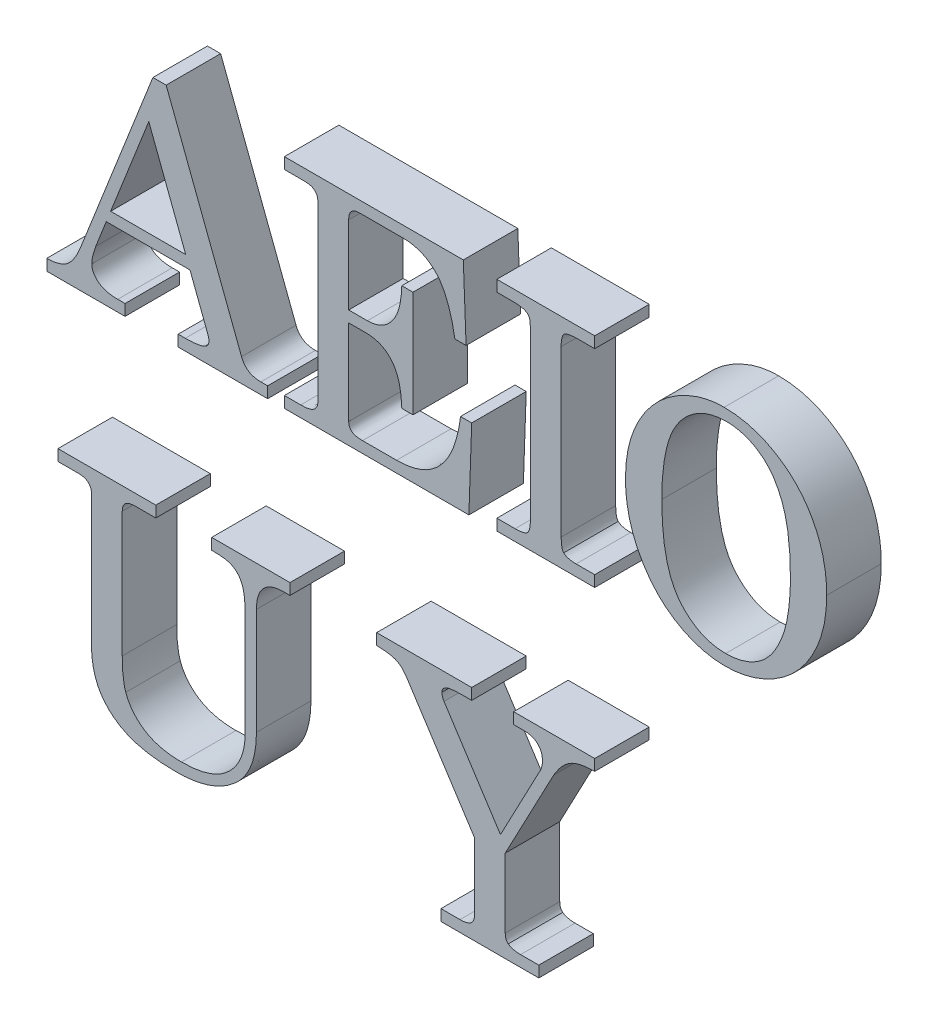
from build123d import *

# Parameters (mm, degrees)
BOSS_EXTRU_1_DEPTH   = 10
BOSS_EXTRU_1_2_DEPTH = 10
BOSS_EXTRU_1_3_DEPTH = 10
BOSS_EXTRU_1_4_DEPTH = 10
BOSS_EXTRU_1_5_DEPTH = 10
BOSS_EXTRU_1_6_DEPTH = 10


with BuildPart() as part:
    # Esquisse1 → Boss.-Extru.1 (new body)
    with BuildSketch(Plane.XY):
        with BuildLine():
            Line((18.958333333, 40.512820513), (21.386217949, 40.512820513))
            Line((21.386217949, 40.512820513), (35.216346154, 4.294871795))
            add(Edge.make_bspline(
                [(35.216346154, 4.294871795), (35.293715697, 4.115735313), (35.44230231, 3.771707393), (35.750096979, 3.310828226), (36.106440865, 2.913571643), (36.534302745, 2.602066852), (37.004103329, 2.341378765), (37.543609805, 2.185182043), (38.130146652, 2.062135417), (38.543575461, 2.05498884), (38.758012821, 2.051282051)],
                knots=[0, 0, 0, 0, 0.000584277, 0.001122092, 0.00165517, 0.002176004, 0.002702965, 0.003257936, 0.003853531, 0.004495358, 0.004495358, 0.004495358, 0.004495358], degree=3))
            Line((38.758012821, 2.051282051), (40, 2.051282051))
            Line((40, 2.051282051), (40, 0))
            Line((40, 0), (23.58974359, 0))
            Line((23.58974359, 0), (23.58974359, 2.051282051))
            Line((23.58974359, 2.051282051), (24.895833333, 2.051282051))
            add(Edge.make_bspline(
                [(24.895833333, 2.051282051), (25.291606746, 2.055123883), (26.023328427, 2.062226816), (27.024118043, 2.168609824), (27.851103363, 2.313529654), (28.311555136, 2.508773405), (28.517628205, 2.596153846)],
                knots=[0, 0, 0, 0, 0.00118633, 0.002193335, 0.003019938, 0.003689572, 0.003689572, 0.003689572, 0.003689572], degree=3))
            add(Edge.make_bspline(
                [(28.517628205, 2.596153846), (28.62577153, 2.663019754), (28.835796861, 2.792880145), (29.078001573, 3.070648089), (29.209963564, 3.411055425), (29.22894197, 3.650097789), (29.238782051, 3.774038462)],
                knots=[0, 0, 0, 0, 0.000380081, 0.000738157, 0.00108336, 0.001455072, 0.001455072, 0.001455072, 0.001455072], degree=3))
            add(Edge.make_bspline(
                [(29.238782051, 3.774038462), (29.230043341, 3.935743885), (29.211768342, 4.273913504), (29.097887182, 4.593071739), (29.038461538, 4.759615385)],
                knots=[0, 0, 0, 0, 0.000483167, 0.001010433, 0.001010433, 0.001010433, 0.001010433], degree=3))
            Line((29.038461538, 4.759615385), (25.761217949, 13.333333333))
            Line((25.761217949, 13.333333333), (10.400641026, 13.333333333))
            Line((10.400641026, 13.333333333), (8.461538462, 8.413461538))
            add(Edge.make_bspline(
                [(8.461538462, 8.413461538), (8.353429909, 8.104853668), (8.151031127, 7.527083869), (7.925051261, 6.697839454), (7.776589784, 5.969414445), (7.751757893, 5.513363495), (7.740384615, 5.304487179)],
                knots=[0, 0, 0, 0, 0.000980613, 0.001835886, 0.002577667, 0.003204513, 0.003204513, 0.003204513, 0.003204513], degree=3))
            add(Edge.make_bspline(
                [(7.740384615, 5.304487179), (7.756259332, 5.086133156), (7.787523509, 4.656099706), (8.027136272, 4.036769056), (8.425811573, 3.48094597), (8.958560052, 2.968733828), (9.648902819, 2.551144519), (10.483918637, 2.261888131), (11.449946708, 2.072995513), (12.141079245, 2.058812203), (12.508012821, 2.051282051)],
                knots=[0, 0, 0, 0, 0.000653966, 0.001287942, 0.001961448, 0.002692549, 0.003490981, 0.0043604, 0.005331572, 0.006430761, 0.006430761, 0.006430761, 0.006430761], degree=3))
            Line((12.508012821, 2.051282051), (13.846153846, 2.051282051))
            Line((13.846153846, 2.051282051), (13.846153846, 0))
            Line((13.846153846, 0), (-0.512820513, 0))
            Line((-0.512820513, 0), (-0.512820513, 2.051282051))
            add(Edge.make_bspline(
                [(-0.512820513, 2.051282051), (-0.140620362, 2.062217567), (0.569217706, 2.083073134), (1.574710131, 2.276651261), (2.461978241, 2.592649194), (3.245588282, 3.060757534), (3.946666124, 3.72030566), (4.573405617, 4.604912331), (5.199502453, 5.696468471), (5.544058395, 6.525673859), (5.729166667, 6.971153846)],
                knots=[0, 0, 0, 0, 0.001115625, 0.002127654, 0.003058004, 0.003927866, 0.004846375, 0.005923317, 0.007168634, 0.008614365, 0.008614365, 0.008614365, 0.008614365], degree=3))
            Line((5.729166667, 6.971153846), (18.958333333, 40.512820513))
        make_face()
        Polygon((18.205128205, 33.125), (11.209935897, 15.384615385), (24.975961538, 15.384615385), align=None, mode=Mode.SUBTRACT)
    extrude(amount=BOSS_EXTRU_1_DEPTH)


with BuildPart() as body_2:
    # Esquisse1 → Boss.-Extru.1 2 (new body)
    with BuildSketch(Plane.XY):
        with BuildLine():
            Line((43.076923077, 40), (75.897435897, 40))
            Line((75.897435897, 40), (76.41025641, 26.666666667))
            Line((76.41025641, 26.666666667), (74.358974359, 26.666666667))
            add(Edge.make_bspline(
                [(74.358974359, 26.666666667), (74.268447848, 27.17266094), (74.093700135, 28.149406206), (73.750130155, 29.542283249), (73.391403829, 30.822918054), (72.968339364, 31.977636571), (72.529218095, 33.026560758), (72.02879529, 33.947740228), (71.504405545, 34.761705441), (70.918646454, 35.449732265), (70.292576846, 36.038991711), (69.638062987, 36.55746773), (68.928523503, 36.986290996), (68.17670044, 37.339245577), (67.377303381, 37.609365805), (66.539409712, 37.815459432), (65.65190403, 37.924080679), (65.04566666, 37.940380572), (64.735576923, 37.948717949)],
                knots=[0, 0, 0, 0, 0.001541651, 0.002975923, 0.004302209, 0.005528982, 0.006663185, 0.007710047, 0.008670115, 0.009562709, 0.010412899, 0.011246386, 0.012062672, 0.012894309, 0.013733056, 0.014590129, 0.015478649, 0.016408999, 0.016408999, 0.016408999, 0.016408999], degree=3))
            Line((64.735576923, 37.948717949), (56.810897436, 37.948717949))
            add(Edge.make_bspline(
                [(56.810897436, 37.948717949), (56.660945513, 37.942918979), (56.376251641, 37.931909244), (55.974395738, 37.840490617), (55.638214311, 37.662842227), (55.348566079, 37.439451283), (55.125100155, 37.137960678), (54.975317557, 36.76890772), (54.888876531, 36.334070668), (54.877744089, 36.023396958), (54.871794872, 35.857371795)],
                knots=[0, 0, 0, 0, 0.000449861, 0.000854092, 0.001223204, 0.001582353, 0.00194293, 0.00233433, 0.00276806, 0.003265888, 0.003265888, 0.003265888, 0.003265888], degree=3))
            Line((54.871794872, 35.857371795), (54.871794872, 21.538461538))
            Line((54.871794872, 21.538461538), (58.301282051, 21.538461538))
            add(Edge.make_bspline(
                [(58.301282051, 21.538461538), (58.526123644, 21.543428941), (58.965024753, 21.553125539), (59.606571218, 21.664212867), (60.216917845, 21.830459608), (60.796247765, 22.062410822), (61.34168821, 22.364856802), (61.853802951, 22.732130031), (62.331095081, 23.174096627), (62.779466781, 23.67460386), (63.183799825, 24.253492608), (63.542737563, 24.899742944), (63.846932384, 25.620862988), (64.101581224, 26.409413548), (64.311756443, 27.268582132), (64.45564057, 28.202127659), (64.574935724, 29.20400333), (64.601614265, 29.898130675), (64.615384615, 30.256410256)],
                knots=[0, 0, 0, 0, 0.00067384, 0.001315366, 0.00194716, 0.002569123, 0.003182404, 0.003813945, 0.00445482, 0.00513023, 0.005826055, 0.006568528, 0.007343952, 0.008170012, 0.009052332, 0.009994205, 0.01100207, 0.012077252, 0.012077252, 0.012077252, 0.012077252], degree=3))
            Line((64.615384615, 30.256410256), (66.666666667, 30.256410256))
            Line((66.666666667, 30.256410256), (66.666666667, 10.769230769))
            Line((66.666666667, 10.769230769), (64.615384615, 10.769230769))
            add(Edge.make_bspline(
                [(64.615384615, 10.769230769), (64.601473179, 11.146158308), (64.574677301, 11.872187152), (64.45880437, 12.917794892), (64.303015509, 13.879294898), (64.09434979, 14.757694864), (63.842193631, 15.556793618), (63.528068756, 16.272557884), (63.170608616, 16.909970247), (62.757064654, 17.464198381), (62.292598974, 17.934558035), (61.806720998, 18.362940279), (61.261710517, 18.700431766), (60.691137736, 19.000448919), (60.069485632, 19.20816999), (59.416756688, 19.372753531), (58.723494881, 19.469658774), (58.248159053, 19.481246879), (58.004807692, 19.487179487)],
                knots=[0, 0, 0, 0, 0.001131199, 0.002178889, 0.003153691, 0.004051591, 0.004885271, 0.005663877, 0.006392383, 0.007073472, 0.007730817, 0.008373093, 0.009011006, 0.009648869, 0.010302688, 0.010971218, 0.011666997, 0.012396868, 0.012396868, 0.012396868, 0.012396868], degree=3))
            Line((58.004807692, 19.487179487), (54.871794872, 19.487179487))
            Line((54.871794872, 19.487179487), (54.871794872, 3.814102564))
            add(Edge.make_bspline(
                [(54.871794872, 3.814102564), (54.880235575, 3.679986785), (54.896383076, 3.423416368), (54.998873707, 3.057423088), (55.191260036, 2.746773791), (55.453121853, 2.477156401), (55.818586023, 2.287598488), (56.264142245, 2.142374842), (56.808804406, 2.071312617), (57.20073488, 2.058294576), (57.411858974, 2.051282051)],
                knots=[0, 0, 0, 0, 0.000402639, 0.00077027, 0.001126187, 0.001488806, 0.001883391, 0.002347098, 0.002889903, 0.003523727, 0.003523727, 0.003523727, 0.003523727], degree=3))
            Line((57.411858974, 2.051282051), (63.653846154, 2.051282051))
            add(Edge.make_bspline(
                [(63.653846154, 2.051282051), (64.068374023, 2.059207302), (64.876358178, 2.07465494), (66.050830084, 2.232498161), (67.160559857, 2.478109644), (68.20213682, 2.831568957), (69.181112804, 3.279197307), (70.083218731, 3.839604986), (70.924213634, 4.491945659), (71.694212491, 5.248698373), (72.396521673, 6.10659886), (73.027490702, 7.064958056), (73.600016825, 8.119298153), (74.094403765, 9.276699645), (74.515492075, 10.535723831), (74.884801289, 11.888206826), (75.183075623, 13.344172809), (75.316123097, 14.352640095), (75.384615385, 14.871794872)],
                knots=[0, 0, 0, 0, 0.001242917, 0.002422654, 0.003548163, 0.004647877, 0.005716229, 0.006770304, 0.007826569, 0.008903153, 0.010001962, 0.011146477, 0.012340415, 0.013596665, 0.014916837, 0.01632027, 0.017800583, 0.019371178, 0.019371178, 0.019371178, 0.019371178], degree=3))
            Line((75.384615385, 14.871794872), (77.435897436, 14.871794872))
            Line((77.435897436, 14.871794872), (76.923076923, 0))
            Line((76.923076923, 0), (43.076923077, 0))
            Line((43.076923077, 0), (43.076923077, 2.051282051))
            Line((43.076923077, 2.051282051), (46.065705128, 2.051282051))
            add(Edge.make_bspline(
                [(46.065705128, 2.051282051), (46.33582522, 2.055845574), (46.835737316, 2.0642913), (47.521600535, 2.162877559), (48.079932032, 2.33421237), (48.517422879, 2.579131147), (48.846005558, 2.897018939), (49.073681868, 3.281751247), (49.202991927, 3.731341508), (49.221204608, 4.048292637), (49.230769231, 4.21474359)],
                knots=[0, 0, 0, 0, 0.000809929, 0.001498939, 0.002071617, 0.002552653, 0.002988966, 0.003427334, 0.00387862, 0.004377736, 0.004377736, 0.004377736, 0.004377736], degree=3))
            Line((49.230769231, 4.21474359), (49.230769231, 35.865384615))
            add(Edge.make_bspline(
                [(49.230769231, 35.865384615), (49.223263492, 36.031571844), (49.209142958, 36.344219575), (49.099387208, 36.785400697), (48.894902682, 37.153213148), (48.611471993, 37.454003933), (48.244718809, 37.682749473), (47.791156294, 37.840540525), (47.252669034, 37.932997837), (46.864709821, 37.943264851), (46.658653846, 37.948717949)],
                knots=[0, 0, 0, 0, 0.000498408, 0.000937654, 0.001350139, 0.001746915, 0.002164813, 0.002633751, 0.003179153, 0.003796972, 0.003796972, 0.003796972, 0.003796972], degree=3))
            Line((46.658653846, 37.948717949), (43.076923077, 37.948717949))
            Line((43.076923077, 37.948717949), (43.076923077, 40))
        make_face()
    extrude(amount=BOSS_EXTRU_1_2_DEPTH)


with BuildPart() as body_3:
    # Esquisse1 → Boss.-Extru.1 3 (new body)
    with BuildSketch(Plane.XY):
        with BuildLine():
            Line((82.051282051, 40), (100, 40))
            Line((100, 40), (100, 37.948717949))
            Line((100, 37.948717949), (96.947115385, 37.948717949))
            add(Edge.make_bspline(
                [(96.947115385, 37.948717949), (96.639733319, 37.943734096), (96.084512475, 37.934731817), (95.339579041, 37.847454955), (94.774433809, 37.693560287), (94.356712631, 37.448620186), (94.108092367, 37.061136317), (93.960450623, 36.561359336), (93.856597721, 35.925600318), (93.849851205, 35.451909208), (93.846153846, 35.192307692)],
                knots=[0, 0, 0, 0, 0.000922032, 0.001665456, 0.002243379, 0.002672346, 0.003081314, 0.003588089, 0.004229615, 0.00500752, 0.00500752, 0.00500752, 0.00500752], degree=3))
            Line((93.846153846, 35.192307692), (93.846153846, 4.943910256))
            add(Edge.make_bspline(
                [(93.846153846, 4.943910256), (93.851171928, 4.670753701), (93.860257165, 4.176203835), (93.947020916, 3.523516419), (94.06456871, 3.012486169), (94.242678841, 2.777049371), (94.318910256, 2.676282051)],
                knots=[0, 0, 0, 0, 0.000817936, 0.001480873, 0.001982811, 0.002358389, 0.002358389, 0.002358389, 0.002358389], degree=3))
            add(Edge.make_bspline(
                [(94.318910256, 2.676282051), (94.440089243, 2.577921871), (94.702100351, 2.365249191), (95.229801907, 2.190801553), (95.864568108, 2.06688902), (96.33186993, 2.056787269), (96.586538462, 2.051282051)],
                knots=[0, 0, 0, 0, 0.000464813, 0.00100501, 0.001641462, 0.002403733, 0.002403733, 0.002403733, 0.002403733], degree=3))
            Line((96.586538462, 2.051282051), (100, 2.051282051))
            Line((100, 2.051282051), (100, 0))
            Line((100, 0), (82.051282051, 0))
            Line((82.051282051, 0), (82.051282051, 2.051282051))
            Line((82.051282051, 2.051282051), (85.400641026, 2.051282051))
            add(Edge.make_bspline(
                [(85.400641026, 2.051282051), (85.668148807, 2.055177851), (86.154935464, 2.062267079), (86.811104782, 2.163573984), (87.31955583, 2.319405366), (87.711442693, 2.566619643), (87.94182072, 2.97305116), (88.103678677, 3.492421091), (88.190630061, 4.169439769), (88.199975307, 4.668649694), (88.205128205, 4.943910256)],
                knots=[0, 0, 0, 0, 0.000801923, 0.001459267, 0.001983786, 0.002392754, 0.002810651, 0.003350373, 0.004022352, 0.004848295, 0.004848295, 0.004848295, 0.004848295], degree=3))
            Line((88.205128205, 4.943910256), (88.205128205, 35.192307692))
            add(Edge.make_bspline(
                [(88.205128205, 35.192307692), (88.198557871, 35.45450186), (88.186786109, 35.924262944), (88.118110107, 36.546417083), (87.98498173, 37.019011566), (87.812860605, 37.233431125), (87.740384615, 37.323717949)],
                knots=[0, 0, 0, 0, 0.00078591, 0.001408079, 0.00188192, 0.002226565, 0.002226565, 0.002226565, 0.002226565], degree=3))
            add(Edge.make_bspline(
                [(87.740384615, 37.323717949), (87.59714034, 37.421653434), (87.280859573, 37.637893213), (86.667503098, 37.823762164), (85.914771324, 37.928333531), (85.363752251, 37.941537499), (85.064102564, 37.948717949)],
                knots=[0, 0, 0, 0, 0.000518114, 0.001143987, 0.001897575, 0.002795905, 0.002795905, 0.002795905, 0.002795905], degree=3))
            Line((85.064102564, 37.948717949), (82.051282051, 37.948717949))
            Line((82.051282051, 37.948717949), (82.051282051, 40))
        make_face()
    extrude(amount=BOSS_EXTRU_1_3_DEPTH)


with BuildPart() as body_4:
    # Esquisse1 → Boss.-Extru.1 4 (new body)
    with BuildSketch(Plane.XY):
        with BuildLine():
            add(Edge.make_bspline(
                [(123.75, 40.512820513), (124.166919014, 40.505026366), (124.994488912, 40.489555253), (126.226885452, 40.368199301), (127.435016972, 40.15547441), (128.62878162, 39.879180562), (129.799199544, 39.505096547), (130.956190962, 39.060366003), (132.083654885, 38.517361379), (133.192784635, 37.911614281), (134.256221452, 37.225940695), (135.274882057, 36.478985087), (136.224658083, 35.660877027), (137.121710704, 34.783003936), (137.954616854, 33.837565267), (138.724263565, 32.82267889), (139.440289103, 31.749146061), (140.084345365, 30.610808338), (140.672555013, 29.428794125), (141.174485531, 28.197563614), (141.6116102, 26.934519503), (141.953060222, 25.628408295), (142.224369623, 24.290711491), (142.429414145, 22.916670198), (142.538874602, 21.502878392), (142.555622791, 20.547712465), (142.564102564, 20.064102564)],
                knots=[0, 0, 0, 0, 0.001250642, 0.002482481, 0.003710222, 0.004928829, 0.006155393, 0.007393419, 0.008644292, 0.009906661, 0.011182487, 0.012437332, 0.013693199, 0.014939753, 0.016200086, 0.017469353, 0.018758322, 0.02006824, 0.02139055, 0.022716375, 0.0240543, 0.025397327, 0.026762919, 0.028147677, 0.029562388, 0.031013262, 0.031013262, 0.031013262, 0.031013262], degree=3))
            add(Edge.make_bspline(
                [(142.564102564, 20.064102564), (142.556798828, 19.580383335), (142.542370086, 18.624782127), (142.415931339, 17.21272787), (142.227204473, 15.836841495), (141.953838817, 14.496036475), (141.600748887, 13.18738429), (141.169460915, 11.912426584), (140.653738236, 10.677823558), (140.070722961, 9.482689911), (139.414553187, 8.341643796), (138.701237282, 7.25696912), (137.930343325, 6.237200682), (137.103471194, 5.278715737), (136.211433384, 4.387189675), (135.259518576, 3.564062531), (134.248988233, 2.805656278), (133.192678244, 2.113406836), (132.094050846, 1.497138422), (130.976011237, 0.959685695), (129.836273493, 0.510055297), (128.687404623, 0.131762507), (127.517474644, -0.161194881), (126.329523579, -0.35396323), (125.126120998, -0.492874577), (124.316641337, -0.506153876), (123.91025641, -0.512820513)],
                knots=[0, 0, 0, 0, 0.001450874, 0.002866243, 0.004249865, 0.005615457, 0.006968295, 0.008313805, 0.009650098, 0.010979598, 0.01230045, 0.013596101, 0.014871752, 0.016132848, 0.017390682, 0.018651779, 0.019904985, 0.021178444, 0.022437707, 0.023681347, 0.024897001, 0.026110751, 0.027307884, 0.028510581, 0.029719322, 0.03093793, 0.03093793, 0.03093793, 0.03093793], degree=3))
            add(Edge.make_bspline(
                [(123.91025641, -0.512820513), (123.514645194, -0.505208398), (122.726938249, -0.49005181), (121.556948145, -0.365505891), (120.40184174, -0.1672024), (119.26863603, 0.125055936), (118.150667558, 0.483634145), (117.052639547, 0.928246736), (115.976503225, 1.458081382), (114.916369988, 2.057663921), (113.893444018, 2.734418051), (112.924709379, 3.493866047), (111.993876109, 4.308229171), (111.137593096, 5.215307494), (110.299658868, 6.16270284), (109.545735803, 7.204720579), (108.828543673, 8.304695275), (108.166377464, 9.466836925), (107.575730297, 10.685998271), (107.052675425, 11.938643087), (106.62163034, 13.231236232), (106.257340194, 14.548343277), (105.988299193, 15.90444327), (105.787433502, 17.286860781), (105.663344539, 18.705000381), (105.648526459, 19.660541803), (105.641025641, 20.144230769)],
                knots=[0, 0, 0, 0, 0.001186574, 0.002362604, 0.003525816, 0.004699633, 0.005870327, 0.007045811, 0.008249896, 0.009466394, 0.010697581, 0.011925322, 0.013157031, 0.01440374, 0.015664836, 0.016948539, 0.0182576, 0.0196033, 0.020957917, 0.022319484, 0.023672583, 0.025042987, 0.026416432, 0.027817049, 0.029232418, 0.030683292, 0.030683292, 0.030683292, 0.030683292], degree=3))
            add(Edge.make_bspline(
                [(105.641025641, 20.144230769), (105.649273388, 20.619869009), (105.665606404, 21.561775635), (105.779225713, 22.958578155), (105.969253337, 24.321036312), (106.244348369, 25.64459847), (106.587027887, 26.933242525), (107.015488168, 28.183792555), (107.509292451, 29.404134855), (108.08610221, 30.581759634), (108.738215633, 31.704917469), (109.427933029, 32.784816407), (110.197326078, 33.787636262), (111.012943494, 34.732486918), (111.880529145, 35.621265728), (112.81260323, 36.437415364), (113.799934063, 37.193066905), (114.83820138, 37.87738784), (115.908292511, 38.493571371), (116.99817556, 39.030350107), (118.097959429, 39.488586341), (119.204850465, 39.867850314), (120.324165207, 40.160253209), (121.456089457, 40.353376269), (122.598047166, 40.492946804), (123.364957302, 40.506177683), (123.75, 40.512820513)],
                knots=[0, 0, 0, 0, 0.001426845, 0.002825581, 0.004201268, 0.005551161, 0.006878704, 0.008198876, 0.009514248, 0.010825832, 0.012128796, 0.013408968, 0.014667007, 0.015916801, 0.017152024, 0.018389739, 0.019630174, 0.020879146, 0.022117509, 0.023332317, 0.024521297, 0.025689439, 0.026839969, 0.027987398, 0.029132419, 0.03028696, 0.03028696, 0.03028696, 0.03028696], degree=3))
        make_face()
        with BuildLine():
            add(Edge.make_bspline(
                [(124.182692308, 38.461538462), (123.751727959, 38.451131181), (122.903218224, 38.430640672), (121.66476321, 38.211870593), (120.488696417, 37.878958381), (119.373065045, 37.407531893), (118.325025968, 36.796904127), (117.337133162, 36.052393394), (116.421628065, 35.167455698), (115.556584268, 34.157585142), (114.783754334, 32.986225848), (114.118893675, 31.647284567), (113.550035352, 30.145004153), (113.102879228, 28.467878527), (112.740752656, 26.626504181), (112.495593414, 24.615279797), (112.327550661, 22.436077081), (112.314476303, 20.927169548), (112.307692308, 20.144230769)],
                knots=[0, 0, 0, 0, 0.001291656, 0.002543093, 0.003760409, 0.004952489, 0.006166028, 0.007390392, 0.008654209, 0.009978751, 0.011372175, 0.012852141, 0.014454906, 0.01618302, 0.018053049, 0.020080546, 0.022257925, 0.024606174, 0.024606174, 0.024606174, 0.024606174], degree=3))
            add(Edge.make_bspline(
                [(112.307692308, 20.144230769), (112.319217702, 19.300010443), (112.341376661, 17.6768951), (112.487743575, 15.343761037), (112.749619811, 13.21364791), (113.112510185, 11.284434354), (113.579318885, 9.555899143), (114.151297637, 8.025866962), (114.83966585, 6.700792436), (115.633281694, 5.571272495), (116.512122188, 4.620044153), (117.437781074, 3.798872644), (118.406843144, 3.0933557), (119.435605715, 2.530527709), (120.50974563, 2.085248287), (121.63493329, 1.761831989), (122.814363261, 1.576606915), (123.615818176, 1.551300656), (124.022435897, 1.538461538)],
                knots=[0, 0, 0, 0, 0.002532672, 0.004869368, 0.007009166, 0.008967248, 0.010753693, 0.012374285, 0.013858107, 0.015220876, 0.016502627, 0.017734335, 0.018928488, 0.020090457, 0.021243691, 0.022410375, 0.023594675, 0.024814309, 0.024814309, 0.024814309, 0.024814309], degree=3))
            add(Edge.make_bspline(
                [(124.022435897, 1.538461538), (124.308373409, 1.545856773), (124.870660344, 1.560399264), (125.704377576, 1.638765532), (126.510126224, 1.784071165), (127.290336556, 1.982929243), (128.041348162, 2.24453633), (128.771952456, 2.551195608), (129.467594871, 2.935552508), (130.146223345, 3.356624112), (130.79131959, 3.848882809), (131.399168783, 4.412839308), (131.979749856, 5.04088063), (132.523415021, 5.737950772), (133.027527007, 6.504147306), (133.502884364, 7.332919233), (133.940418238, 8.231246561), (134.350677388, 9.195236216), (134.724012404, 10.230721491), (135.027375159, 11.347907241), (135.308067562, 12.53777542), (135.513541563, 13.810873127), (135.695993357, 15.156594919), (135.810713096, 16.582244039), (135.884595879, 18.084135721), (135.89309115, 19.113151969), (135.897435897, 19.639423077)],
                knots=[0, 0, 0, 0, 0.000857971, 0.001687172, 0.002509218, 0.003311862, 0.004099934, 0.004893243, 0.005685581, 0.006481436, 0.007287552, 0.008115474, 0.008966042, 0.009850833, 0.010764224, 0.011715356, 0.012715162, 0.013759937, 0.014857342, 0.016014134, 0.017230922, 0.018523199, 0.019880846, 0.021304199, 0.022812335, 0.024391043, 0.024391043, 0.024391043, 0.024391043], degree=3))
            add(Edge.make_bspline(
                [(135.897435897, 19.639423077), (135.892047469, 20.211038319), (135.881569281, 21.322585538), (135.822887316, 22.942607633), (135.698812408, 24.468056957), (135.541557009, 25.895381169), (135.346356926, 27.228774805), (135.086689426, 28.460010085), (134.796083154, 29.602018332), (134.447946456, 30.64942669), (134.061585554, 31.617583843), (133.637475103, 32.51760071), (133.172142925, 33.353113621), (132.67005145, 34.12490562), (132.11879825, 34.825956464), (131.538260749, 35.466944013), (130.913352242, 36.043346448), (130.251632603, 36.552433985), (129.55990857, 36.999570023), (128.853918948, 37.397664329), (128.123757661, 37.725271048), (127.372835568, 37.991175228), (126.603690229, 38.198209579), (125.814460246, 38.3536105), (125.004648111, 38.44102983), (124.45799554, 38.454669366), (124.182692308, 38.461538462)],
                knots=[0, 0, 0, 0, 0.001714912, 0.003334771, 0.004861944, 0.006305164, 0.007642369, 0.008902702, 0.010078513, 0.011175684, 0.012211293, 0.013204139, 0.014158304, 0.015078384, 0.015963175, 0.016830968, 0.017670213, 0.018510031, 0.019332351, 0.020139422, 0.02093918, 0.021729895, 0.022526839, 0.023326717, 0.024140798, 0.02496674, 0.02496674, 0.02496674, 0.02496674], degree=3))
        make_face(mode=Mode.SUBTRACT)
    extrude(amount=BOSS_EXTRU_1_4_DEPTH)


with BuildPart() as body_5:
    # Esquisse1 → Boss.-Extru.1 5 (new body)
    with BuildSketch(Plane.XY):
        with BuildLine():
            Line((1.538461538, -27.153846154), (19.487179487, -27.153846154))
            Line((19.487179487, -27.153846154), (19.487179487, -29.205128205))
            Line((19.487179487, -29.205128205), (15.913461538, -29.205128205))
            add(Edge.make_bspline(
                [(15.913461538, -29.205128205), (15.691596146, -29.211321387), (15.283175876, -29.222722087), (14.718491246, -29.301953208), (14.262082321, -29.462105849), (13.897212441, -29.678759553), (13.637578975, -29.977197956), (13.459969567, -30.335928072), (13.345094418, -30.75532232), (13.337374042, -31.057954064), (13.333333333, -31.216346154)],
                knots=[0, 0, 0, 0, 0.000665836, 0.001225702, 0.001702179, 0.002109022, 0.002483659, 0.002870687, 0.003302191, 0.003776032, 0.003776032, 0.003776032, 0.003776032], degree=3))
            Line((13.333333333, -31.216346154), (13.333333333, -54.197115385))
            add(Edge.make_bspline(
                [(13.333333333, -54.197115385), (13.333915923, -54.488293782), (13.335044084, -55.052149009), (13.37088498, -55.872192554), (13.414287563, -56.636890285), (13.486907513, -57.347963279), (13.581759356, -58.000145996), (13.696121729, -58.598375017), (13.817366092, -59.144090425), (13.929030338, -59.483634711), (13.982371795, -59.645833333)],
                knots=[0, 0, 0, 0, 0.000873434, 0.00169137, 0.002462102, 0.003170908, 0.003834958, 0.004438425, 0.004998176, 0.00551012, 0.00551012, 0.00551012, 0.00551012], degree=3))
            add(Edge.make_bspline(
                [(13.982371795, -59.645833333), (14.066524983, -59.869219378), (14.232840581, -60.310706912), (14.552068834, -60.942423611), (14.918080545, -61.540839528), (15.335685701, -62.104830545), (15.807789691, -62.627401493), (16.316801506, -63.125987246), (16.884440324, -63.584556132), (17.498124342, -64.009278302), (18.166388031, -64.386329993), (18.882473026, -64.714058945), (19.646831723, -64.999440049), (20.465118543, -65.213544592), (21.325945472, -65.40943939), (22.239072522, -65.515968183), (23.1980126, -65.60606568), (23.853914309, -65.61222298), (24.190705128, -65.615384615)],
                knots=[0, 0, 0, 0, 0.000715702, 0.001414474, 0.002119465, 0.00281819, 0.003516226, 0.004230222, 0.004953554, 0.00570257, 0.006466861, 0.007252035, 0.008063272, 0.008910815, 0.00978777, 0.010709105, 0.011665992, 0.012675893, 0.012675893, 0.012675893, 0.012675893], degree=3))
            add(Edge.make_bspline(
                [(24.190705128, -65.615384615), (24.653066146, -65.605295104), (25.550234645, -65.585717348), (26.855470141, -65.459226109), (28.07688183, -65.239577291), (29.211169702, -64.913512552), (30.268768915, -64.519657779), (31.235242811, -64.019148222), (32.116319365, -63.429849212), (32.912685884, -62.755473726), (33.615208683, -62.001742126), (34.229322674, -61.188816019), (34.747140017, -60.312421201), (35.172464863, -59.378481933), (35.490580802, -58.375952658), (35.73514679, -57.321469141), (35.868315264, -56.201046221), (35.887592325, -55.436751321), (35.897435897, -55.046474359)],
                knots=[0, 0, 0, 0, 0.001387051, 0.002691444, 0.003929885, 0.005104276, 0.006227815, 0.00731011, 0.008361287, 0.009401627, 0.010433385, 0.011446207, 0.012452127, 0.01348133, 0.014517713, 0.015602378, 0.016724459, 0.017895318, 0.017895318, 0.017895318, 0.017895318], degree=3))
            Line((35.897435897, -55.046474359), (35.897435897, -36.360576923))
            add(Edge.make_bspline(
                [(35.897435897, -36.360576923), (35.891340206, -35.973296716), (35.879898571, -35.246370292), (35.835510486, -34.228545095), (35.720760804, -33.362158782), (35.579179185, -32.629579073), (35.394051802, -32.009152036), (35.167060386, -31.47245575), (34.90613446, -31.002996412), (34.595045353, -30.606207325), (34.254235424, -30.263339526), (33.87282344, -29.970013499), (33.445141374, -29.731226435), (32.957750803, -29.528483448), (32.368597624, -29.374726021), (31.634612201, -29.279357386), (30.743571801, -29.217992213), (30.093611328, -29.209630966), (29.743589744, -29.205128205)],
                knots=[0, 0, 0, 0, 0.001162108, 0.00218128, 0.003053906, 0.003781486, 0.004417736, 0.004992205, 0.005526907, 0.006023767, 0.006499704, 0.006974087, 0.007462081, 0.007965041, 0.008553969, 0.009282608, 0.01018233, 0.011232285, 0.011232285, 0.011232285, 0.011232285], degree=3))
            Line((29.743589744, -29.205128205), (29.743589744, -27.153846154))
            Line((29.743589744, -27.153846154), (44.102564103, -27.153846154))
            Line((44.102564103, -27.153846154), (44.102564103, -29.205128205))
            Line((44.102564103, -29.205128205), (43.012820513, -29.205128205))
            add(Edge.make_bspline(
                [(43.012820513, -29.205128205), (42.613666033, -29.221694398), (41.860061159, -29.252971421), (40.799600175, -29.49385926), (39.905765396, -29.935087265), (39.167470915, -30.539247889), (38.614367476, -31.321157429), (38.219525544, -32.246289745), (37.990102456, -33.323450946), (37.963022681, -34.089126251), (37.948717949, -34.493589744)],
                knots=[0, 0, 0, 0, 0.001197159, 0.002260241, 0.003234943, 0.004162391, 0.005092016, 0.006078927, 0.007161845, 0.008374431, 0.008374431, 0.008374431, 0.008374431], degree=3))
            Line((37.948717949, -34.493589744), (37.948717949, -54.020833333))
            add(Edge.make_bspline(
                [(37.948717949, -54.020833333), (37.939342695, -54.539542539), (37.921113838, -55.548099396), (37.740103593, -57.011916199), (37.453353606, -58.382601014), (37.057004735, -59.664029936), (36.530560542, -60.849813525), (35.897191649, -61.947308909), (35.143003463, -62.951731339), (34.550864796, -63.536268922), (34.254807692, -63.828525641)],
                knots=[0, 0, 0, 0, 0.001555499, 0.003024448, 0.004416835, 0.005752383, 0.00704028, 0.008300537, 0.009547348, 0.010794056, 0.010794056, 0.010794056, 0.010794056], degree=3))
            add(Edge.make_bspline(
                [(34.254807692, -63.828525641), (33.899997187, -64.134920041), (33.191184297, -64.747010994), (32.020159175, -65.5378284), (30.757903747, -66.190886803), (29.413709262, -66.732265236), (27.987476052, -67.158737664), (26.470180004, -67.447235794), (24.871485598, -67.641228702), (23.77464499, -67.658053548), (23.213141026, -67.666666667)],
                knots=[0, 0, 0, 0, 0.001405536, 0.002807872, 0.004227136, 0.005661521, 0.007149685, 0.008684993, 0.010290159, 0.011973786, 0.011973786, 0.011973786, 0.011973786], degree=3))
            add(Edge.make_bspline(
                [(23.213141026, -67.666666667), (22.72956834, -67.66306205), (21.78575524, -67.656026739), (20.411951266, -67.572323856), (19.117199919, -67.448737484), (17.902539998, -67.264966395), (16.765951282, -67.024992257), (15.708001515, -66.739423023), (14.729087862, -66.403047454), (13.830072831, -66.009232429), (12.999058509, -65.567765277), (12.233115971, -65.073076728), (11.518688149, -64.540293113), (10.868440566, -63.953945263), (10.282332422, -63.321724819), (9.737422918, -62.658070003), (9.266399101, -61.934351935), (8.997204224, -61.424170013), (8.862179487, -61.168269231)],
                knots=[0, 0, 0, 0, 0.00145052, 0.002831052, 0.004127471, 0.005351362, 0.006514298, 0.007610621, 0.008636919, 0.009616484, 0.010552099, 0.011456732, 0.012349361, 0.01322309, 0.014079112, 0.014933822, 0.015796122, 0.016663914, 0.016663914, 0.016663914, 0.016663914], degree=3))
            add(Edge.make_bspline(
                [(8.862179487, -61.168269231), (8.678497253, -60.747983426), (8.298055221, -59.877488867), (7.960271388, -58.430833766), (7.724806606, -56.843857886), (7.703452073, -55.73127131), (7.692307692, -55.150641026)],
                knots=[0, 0, 0, 0, 0.001373375, 0.00284453, 0.00443892, 0.006179197, 0.006179197, 0.006179197, 0.006179197], degree=3))
            Line((7.692307692, -55.150641026), (7.692307692, -31.168269231))
            add(Edge.make_bspline(
                [(7.692307692, -31.168269231), (7.684474858, -31.023371674), (7.66942029, -30.744881162), (7.558418675, -30.350213657), (7.356065623, -30.009264105), (7.080256635, -29.718465861), (6.726041907, -29.480649919), (6.294166575, -29.31447737), (5.786610005, -29.220613166), (5.425100599, -29.21051289), (5.232371795, -29.205128205)],
                knots=[0, 0, 0, 0, 0.000434543, 0.000835184, 0.001215856, 0.001612633, 0.002028219, 0.00248502, 0.002991035, 0.003568848, 0.003568848, 0.003568848, 0.003568848], degree=3))
            Line((5.232371795, -29.205128205), (1.538461538, -29.205128205))
            Line((1.538461538, -29.205128205), (1.538461538, -27.153846154))
        make_face()
    extrude(amount=BOSS_EXTRU_1_5_DEPTH)


with BuildPart() as body_6:
    # Esquisse1 → Boss.-Extru.1 6 (new body)
    with BuildSketch(Plane.XY):
        with BuildLine():
            Line((60, -27.153846154), (77.435897436, -27.153846154))
            Line((77.435897436, -27.153846154), (77.435897436, -29.205128205))
            Line((77.435897436, -29.205128205), (75.625, -29.205128205))
            add(Edge.make_bspline(
                [(75.625, -29.205128205), (75.280189623, -29.208149642), (74.656429041, -29.213615408), (73.819070234, -29.28703486), (73.168510843, -29.381251555), (72.693518149, -29.549022901), (72.36572901, -29.76726702), (72.147222958, -30.021146096), (71.995757663, -30.309001621), (71.984761824, -30.522680977), (71.979166667, -30.631410256)],
                knots=[0, 0, 0, 0, 0.001033933, 0.001870381, 0.002521149, 0.00300038, 0.003369317, 0.003687417, 0.003999197, 0.004322205, 0.004322205, 0.004322205, 0.004322205], degree=3))
            add(Edge.make_bspline(
                [(71.979166667, -30.631410256), (71.995446653, -30.857806455), (72.027793425, -31.307634003), (72.246925401, -31.701701042), (72.355769231, -31.897435897)],
                knots=[0, 0, 0, 0, 0.000671979, 0.001335158, 0.001335158, 0.001335158, 0.001335158], degree=3))
            Line((72.355769231, -31.897435897), (82.716346154, -47.891025641))
            Line((82.716346154, -47.891025641), (89.927884615, -34.213141026))
            add(Edge.make_bspline(
                [(89.927884615, -34.213141026), (90.004275124, -34.062731164), (90.155738965, -33.764504908), (90.307659647, -33.283598134), (90.396540887, -32.784857153), (90.409917495, -32.445341299), (90.416666667, -32.274038462)],
                knots=[0, 0, 0, 0, 0.00050538, 0.001002045, 0.001506599, 0.00202042, 0.00202042, 0.00202042, 0.00202042], degree=3))
            add(Edge.make_bspline(
                [(90.416666667, -32.274038462), (90.406878963, -32.051198728), (90.388052384, -31.622568046), (90.215107683, -31.011589159), (89.923385084, -30.475831167), (89.519964206, -30.018445633), (89.019685448, -29.641583031), (88.407164212, -29.390370804), (87.709214461, -29.223662139), (87.209972968, -29.211520793), (86.947115385, -29.205128205)],
                knots=[0, 0, 0, 0, 0.000667425, 0.001283788, 0.00188619, 0.002482432, 0.00310103, 0.003747044, 0.004454536, 0.005241263, 0.005241263, 0.005241263, 0.005241263], degree=3))
            Line((86.947115385, -29.205128205), (85.128205128, -29.205128205))
            Line((85.128205128, -29.205128205), (85.128205128, -27.153846154))
            Line((85.128205128, -27.153846154), (100, -27.153846154))
            Line((100, -27.153846154), (100, -29.205128205))
            add(Edge.make_bspline(
                [(100, -29.205128205), (99.558760419, -29.214890823), (98.720782343, -29.233431454), (97.533228051, -29.397835503), (96.491224233, -29.681809745), (95.56550896, -30.091223288), (94.738489465, -30.683530181), (93.945173941, -31.453964944), (93.172661407, -32.426661048), (92.711167807, -33.171534793), (92.467948718, -33.564102564)],
                knots=[0, 0, 0, 0, 0.001323305, 0.002513148, 0.003586297, 0.00455449, 0.00553258, 0.006620672, 0.007863306, 0.009247948, 0.009247948, 0.009247948, 0.009247948], degree=3))
            Line((92.467948718, -33.564102564), (83.58974359, -50.391025641))
            Line((83.58974359, -50.391025641), (83.58974359, -63.091346154))
            add(Edge.make_bspline(
                [(83.58974359, -63.091346154), (83.594598925, -63.246899375), (83.603768806, -63.540680252), (83.705049449, -63.946928487), (83.88451181, -64.285462478), (84.057742432, -64.45203208), (84.142628205, -64.533653846)],
                knots=[0, 0, 0, 0, 0.000465847, 0.000879809, 0.001245601, 0.001597071, 0.001597071, 0.001597071, 0.001597071], degree=3))
            add(Edge.make_bspline(
                [(84.142628205, -64.533653846), (84.281042791, -64.622974813), (84.574152109, -64.812122566), (85.108931885, -64.97380574), (85.723735575, -65.093081579), (86.166426293, -65.099268426), (86.40224359, -65.102564103)],
                knots=[0, 0, 0, 0, 0.00049199, 0.001041847, 0.001661067, 0.002366924, 0.002366924, 0.002366924, 0.002366924], degree=3))
            Line((86.40224359, -65.102564103), (89.743589744, -65.102564103))
            Line((89.743589744, -65.102564103), (89.743589744, -67.153846154))
            Line((89.743589744, -67.153846154), (71.794871795, -67.153846154))
            Line((71.794871795, -67.153846154), (71.794871795, -65.102564103))
            Line((71.794871795, -65.102564103), (75.288461538, -65.102564103))
            add(Edge.make_bspline(
                [(75.288461538, -65.102564103), (75.508103996, -65.098468226), (75.918225624, -65.090820307), (76.480840546, -64.984099031), (76.954621247, -64.832209985), (77.326650482, -64.593561766), (77.608056089, -64.29369084), (77.816151986, -63.942704771), (77.925312877, -63.530286474), (77.940712172, -63.241487037), (77.948717949, -63.091346154)],
                knots=[0, 0, 0, 0, 0.000657833, 0.001228321, 0.001712351, 0.002141317, 0.002538094, 0.002936646, 0.003352696, 0.003803199, 0.003803199, 0.003803199, 0.003803199], degree=3))
            Line((77.948717949, -63.091346154), (77.948717949, -50.743589744))
            Line((77.948717949, -50.743589744), (65.488782051, -31.496794872))
            add(Edge.make_bspline(
                [(65.488782051, -31.496794872), (65.351622199, -31.30114633), (65.088548601, -30.925890999), (64.6358516, -30.434332409), (64.14090928, -30.046965304), (63.594650286, -29.730851702), (62.933430973, -29.500465589), (62.114906592, -29.355583605), (61.119327579, -29.242197012), (60.39303117, -29.218144231), (60, -29.205128205)],
                knots=[0, 0, 0, 0, 0.000716375, 0.001374012, 0.001995974, 0.002595278, 0.003259327, 0.004084336, 0.005084239, 0.006263458, 0.006263458, 0.006263458, 0.006263458], degree=3))
            Line((60, -29.205128205), (60, -27.153846154))
        make_face()
    extrude(amount=BOSS_EXTRU_1_6_DEPTH)


solid = Compound([part.part, body_2.part, body_3.part, body_4.part, body_5.part, body_6.part])
